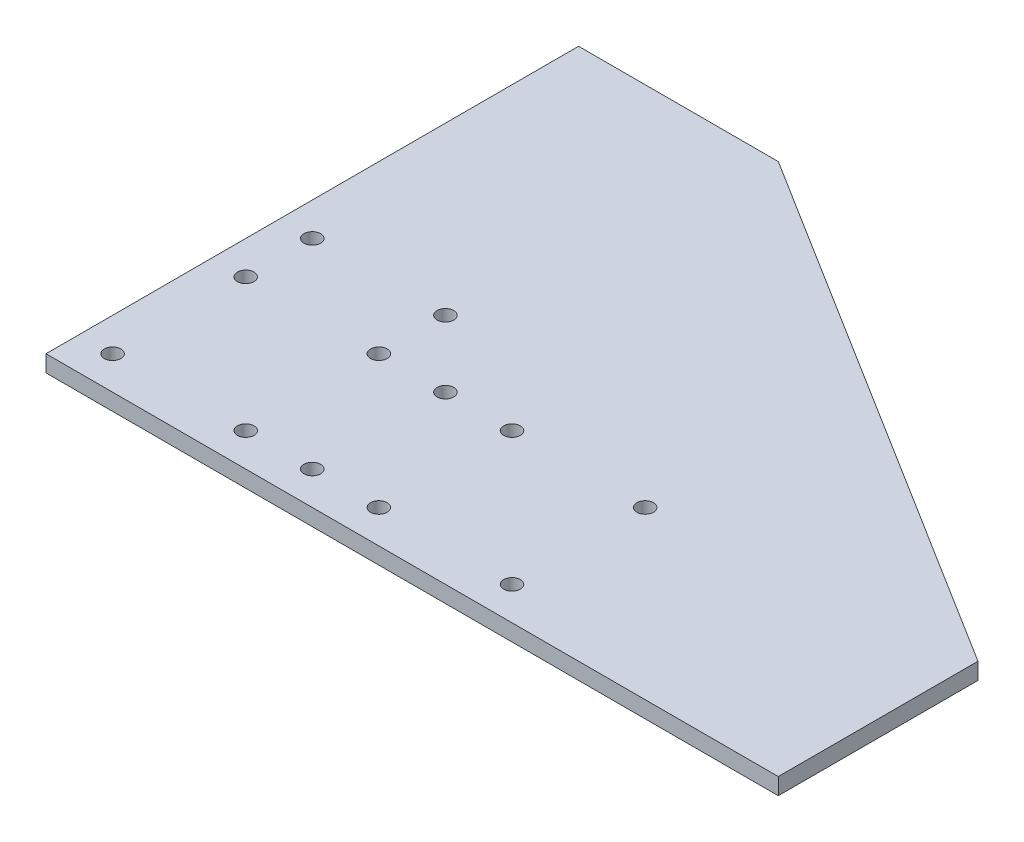
from build123d import *

# Parameters (mm, degrees)
BOSS_EXTRUDE1_DEPTH = 3.175
SKETCH2_R           = 1.5875
CUT_EXTRUDE1_DEPTH  = 4.175
BOSS_EXTRUDE2_DEPTH = 3.175


with BuildPart() as part:
    # Sketch1 → Boss-Extrude1 (new body)
    with BuildSketch(Plane(origin=(0, 0, 0), x_dir=(1, 0, 0), z_dir=(0, 1, 0))):
        Polygon((0, 50.8), (0, 0), (88.9, 0), (88.9, 38.1), (38.1, 38.1), (38.1, 50.8), align=None)
    extrude(amount=BOSS_EXTRUDE1_DEPTH)

    # Sketch2 → Cut-Extrude1 (cut, through all)
    with BuildSketch(Plane(origin=(0, 3.175, 0), x_dir=(1, 0, 0), z_dir=(0, 1, 0))):
        with Locations((6.35, 44.45)):
            Circle(SKETCH2_R)
        with Locations((31.75, 44.45)):
            Circle(SKETCH2_R)
        with Locations((31.75, 31.75)):
            Circle(SKETCH2_R)
        with Locations((6.35, 31.75)):
            Circle(SKETCH2_R)
        with Locations((6.35, 6.35)):
            Circle(SKETCH2_R)
        with Locations((31.75, 6.35)):
            Circle(SKETCH2_R)
        with Locations((82.55, 6.35)):
            Circle(SKETCH2_R)
        with Locations((82.55, 31.75)):
            Circle(SKETCH2_R)
        with Locations((57.15, 31.75)):
            Circle(SKETCH2_R)
        with Locations((57.15, 6.35)):
            Circle(SKETCH2_R)
        with Locations((44.45, 6.35)):
            Circle(SKETCH2_R)
        with Locations((44.45, 31.75)):
            Circle(SKETCH2_R)
    extrude(amount=-CUT_EXTRUDE1_DEPTH, mode=Mode.SUBTRACT)

    # Sketch3 → Boss-Extrude2 (add)
    with BuildSketch(Plane(origin=(0, 3.175, 0), x_dir=(1, 0, 0), z_dir=(0, 1, 0))):
        Polygon((0, 101.6), (38.1, 101.6), (139.7, 38.1), (139.7, 0), (88.9, 0), (88.9, 38.1), (38.1, 38.1), (38.1, 50.8), (0, 50.8), align=None)
    extrude(amount=-BOSS_EXTRUDE2_DEPTH)


solid = part.part
